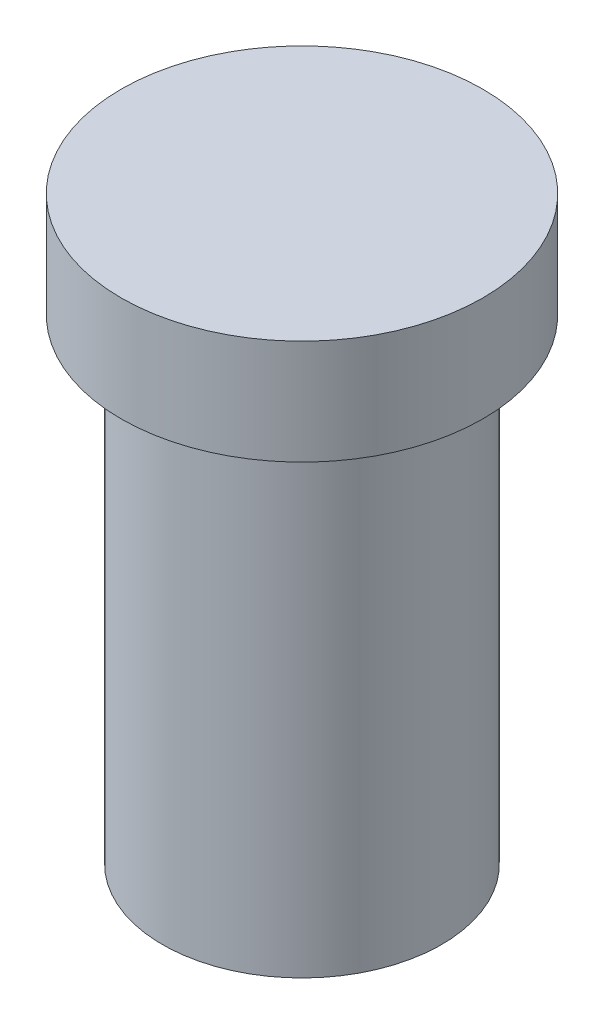
from build123d import *

# Parameters (mm, degrees)
FILLET1_R = 3


with BuildPart() as part:
    # Sketch1 → Revolve3 (revolve)
    with BuildSketch(Plane.XY, mode=Mode.PRIVATE) as revolve3_sk:
        Polygon((0, 0), (22, 0), (22, 75), (28.5, 75), (28.5, 91.510913706), (0, 91.510913706), align=None)
    revolve(revolve3_sk.sketch.rotate(Axis((0, 0, 0), (0, 1, 0)), 90), axis=Axis((0, 0, 0), (0, 1, 0)))  # turned: the seam where the file's is

    # Fillet1
    fillet1_edges = [part.edges().sort_by_distance(p)[0] for p in [
        (0, 75, 22),
    ]]
    fillet(fillet1_edges, radius=FILLET1_R)


solid = part.part
